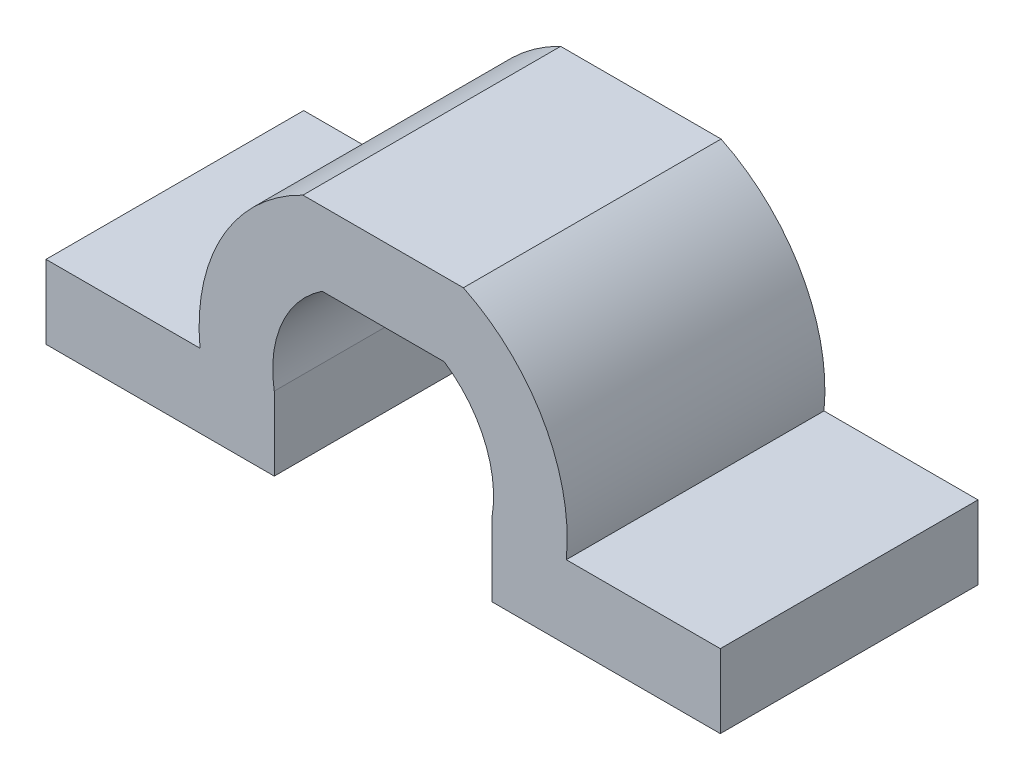
from build123d import *

# Parameters (mm, degrees)
SALIENTE_EXTRUIR2_DEPTH = 14


with BuildPart() as part:
    # Croquis1 → Saliente-Extruir2 (new body)
    with BuildSketch(Plane.XY):
        with BuildLine():
            Line((-3.31662479, 5), (3.31662479, 5))
            ThreePointArc((3.31662479, 5), (5.505516182, 2.385223588), (5.916079783, -1))
            Line((5.916079783, -1), (5.916079783, -5))
            Line((5.916079783, -5), (18.31662479, -5))
            Line((18.31662479, -5), (18.31662479, -1))
            Line((18.31662479, -1), (9.949874371, -1))
            ThreePointArc((9.949874371, -1), (8.728416147, 4.88003602), (4.358898944, 9))
            Line((4.358898944, 9), (-4.358898944, 9))
            ThreePointArc((-4.358898944, 9), (-8.728416147, 4.88003602), (-9.949874371, -1))
            Line((-9.949874371, -1), (-18.31662479, -1))
            Line((-18.31662479, -1), (-18.31662479, -5))
            Line((-18.31662479, -5), (-5.916079783, -5))
            Line((-5.916079783, -5), (-5.916079783, -1))
            ThreePointArc((-5.916079783, -1), (-5.505516182, 2.385223588), (-3.31662479, 5))
        make_face()
    extrude(amount=SALIENTE_EXTRUIR2_DEPTH)


solid = part.part
